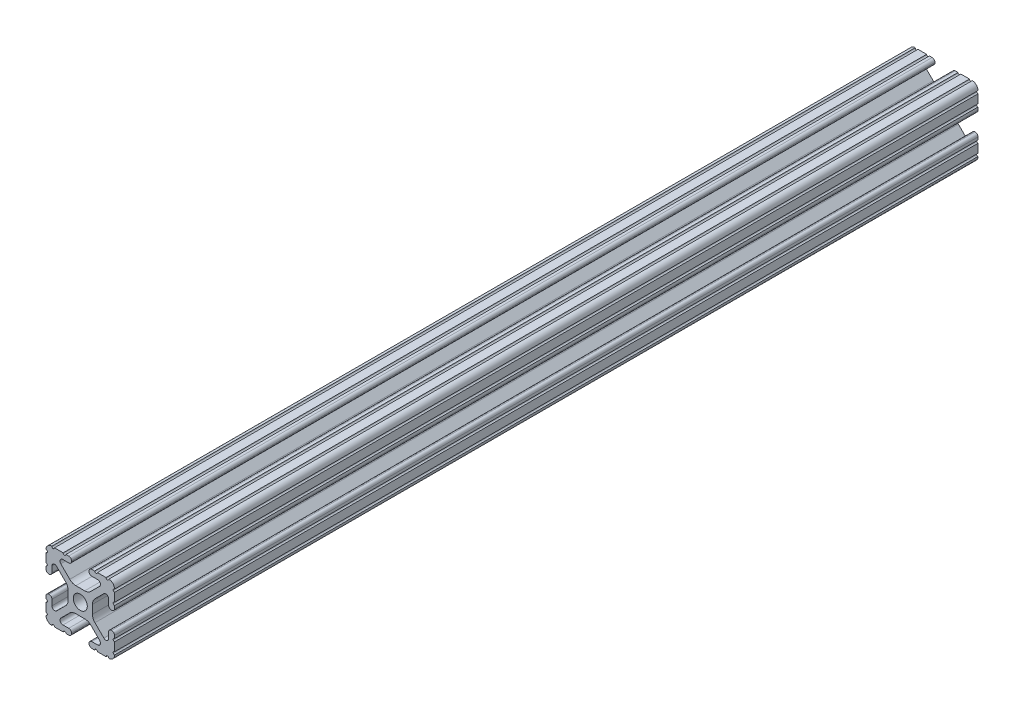
from build123d import *

# Parameters (mm, degrees)
SKETCH1_R      = 2.6035
EXTRUDE1_DEPTH = 320


with BuildPart() as part:
    # Sketch1 → Extrude1 (new body)
    with BuildSketch(Plane.XY):
        with BuildLine():
            Line((-7.207036008, 8.724370562), (-3.898272566, 5.423169045))
            ThreePointArc((-3.898272566, 5.423169045), (-2.869120213, 4.736787962), (-1.655778399, 4.4958))
            Line((-1.655778399, 4.4958), (1.655778399, 4.4958))
            ThreePointArc((1.655778399, 4.4958), (2.869120213, 4.736787962), (3.898272566, 5.423169045))
            Line((3.898272566, 5.423169045), (7.207036008, 8.724370562))
            ThreePointArc((7.207036008, 8.724370562), (7.432222385, 9.85140422), (6.476788598, 10.4902))
            Line((6.476788598, 10.4902), (4.287512407, 10.4902))
            ThreePointArc((4.287512407, 10.4902), (3.54574862, 10.79744862), (3.2385, 11.539212407))
            Line((3.2385, 11.539212407), (3.2385, 11.650987593))
            ThreePointArc((3.2385, 11.650987593), (3.54574862, 12.39275138), (4.287512407, 12.7))
            Line((4.287512407, 12.7), (5.317126718, 12.7))
            ThreePointArc((5.317126718, 12.7), (5.825126718, 12.192), (6.333126718, 12.7))
            Line((6.333126718, 12.7), (9.550443118, 12.7))
            ThreePointArc((9.550443118, 12.7), (10.058366869, 12.192000006), (10.566443095, 12.699847501))
            ThreePointArc((10.566443095, 12.699847501), (12.082537762, 12.08250727), (12.699846982, 10.566399977))
            ThreePointArc((12.699846982, 10.566399977), (12.192000006, 10.058323491), (12.7, 9.5504))
            Line((12.7, 9.5504), (12.7, 6.3330836))
            ThreePointArc((12.7, 6.3330836), (12.192, 5.8250836), (12.7, 5.3170836))
            Line((12.7, 5.3170836), (12.7, 4.287469289))
            ThreePointArc((12.7, 4.287469289), (12.39275138, 3.545705502), (11.650987593, 3.238456882))
            Line((11.650987593, 3.238456882), (11.539212407, 3.238456882))
            ThreePointArc((11.539212407, 3.238456882), (10.79744862, 3.545705502), (10.4902, 4.287469289))
            Line((10.4902, 4.287469289), (10.4902, 6.402089023))
            ThreePointArc((10.4902, 6.402089023), (9.856505071, 7.351067942), (8.737131347, 7.129408934))
            Line((8.737131347, 7.129408934), (5.441005833, 3.840816462))
            ThreePointArc((5.441005833, 3.840816462), (4.750877967, 2.809883091), (4.5085, 1.593185507))
            Line((4.5085, 1.593185507), (4.5085, -1.593185507))
            ThreePointArc((4.5085, -1.593185507), (4.750877967, -2.809883091), (5.441005833, -3.840816462))
            Line((5.441005833, -3.840816462), (8.737131347, -7.129408934))
            ThreePointArc((8.737131347, -7.129408934), (9.856505071, -7.351067942), (10.4902, -6.402089023))
            Line((10.4902, -6.402089023), (10.4902, -4.287469289))
            ThreePointArc((10.4902, -4.287469289), (10.79744862, -3.545705502), (11.539212407, -3.238456882))
            Line((11.539212407, -3.238456882), (11.650987593, -3.238456882))
            ThreePointArc((11.650987593, -3.238456882), (12.39275138, -3.545705502), (12.7, -4.287469289))
            Line((12.7, -4.287469289), (12.7, -5.3170836))
            ThreePointArc((12.7, -5.3170836), (12.192, -5.8250836), (12.7, -6.3330836))
            Line((12.7, -6.3330836), (12.7, -9.5504))
            ThreePointArc((12.7, -9.5504), (12.192000006, -10.058323491), (12.699846982, -10.566399977))
            ThreePointArc((12.699846982, -10.566399977), (12.082537762, -12.08250727), (10.566443095, -12.699847501))
            ThreePointArc((10.566443095, -12.699847501), (10.058366869, -12.192000006), (9.550443118, -12.7))
            Line((9.550443118, -12.7), (6.333126718, -12.7))
            ThreePointArc((6.333126718, -12.7), (5.825126718, -12.192), (5.317126718, -12.7))
            Line((5.317126718, -12.7), (4.287512407, -12.7))
            ThreePointArc((4.287512407, -12.7), (3.54574862, -12.39275138), (3.2385, -11.650987593))
            Line((3.2385, -11.650987593), (3.2385, -11.539212407))
            ThreePointArc((3.2385, -11.539212407), (3.54574862, -10.79744862), (4.287512407, -10.4902))
            Line((4.287512407, -10.4902), (6.416408329, -10.4902))
            ThreePointArc((6.416408329, -10.4902), (7.41473083, -9.822813117), (7.179650497, -8.645192506))
            Line((7.179650497, -8.645192506), (3.952270251, -5.423690499))
            ThreePointArc((3.952270251, -5.423690499), (2.922936451, -4.736929036), (1.709253557, -4.4958))
            Line((1.709253557, -4.4958), (-1.709253557, -4.4958))
            ThreePointArc((-1.709253557, -4.4958), (-2.922936451, -4.736929036), (-3.952270251, -5.423690499))
            Line((-3.952270251, -5.423690499), (-7.179650497, -8.645192506))
            ThreePointArc((-7.179650497, -8.645192506), (-7.41473083, -9.822813117), (-6.416408329, -10.4902))
            Line((-6.416408329, -10.4902), (-4.287512407, -10.4902))
            ThreePointArc((-4.287512407, -10.4902), (-3.54574862, -10.79744862), (-3.2385, -11.539212407))
            Line((-3.2385, -11.539212407), (-3.2385, -11.650987593))
            ThreePointArc((-3.2385, -11.650987593), (-3.54574862, -12.39275138), (-4.287512407, -12.7))
            Line((-4.287512407, -12.7), (-5.317126718, -12.7))
            ThreePointArc((-5.317126718, -12.7), (-5.825126718, -12.192), (-6.333126718, -12.7))
            Line((-6.333126718, -12.7), (-9.550443118, -12.7))
            ThreePointArc((-9.550443118, -12.7), (-10.058366869, -12.192000006), (-10.566443095, -12.699847501))
            ThreePointArc((-10.566443095, -12.699847501), (-12.082537762, -12.08250727), (-12.699846982, -10.566399977))
            ThreePointArc((-12.699846982, -10.566399977), (-12.192000006, -10.058323491), (-12.7, -9.5504))
            Line((-12.7, -9.5504), (-12.7, -6.3330836))
            ThreePointArc((-12.7, -6.3330836), (-12.192, -5.8250836), (-12.7, -5.3170836))
            Line((-12.7, -5.3170836), (-12.7, -4.287469289))
            ThreePointArc((-12.7, -4.287469289), (-12.39275138, -3.545705502), (-11.650987593, -3.238456882))
            Line((-11.650987593, -3.238456882), (-11.539212407, -3.238456882))
            ThreePointArc((-11.539212407, -3.238456882), (-10.79744862, -3.545705502), (-10.4902, -4.287469289))
            Line((-10.4902, -4.287469289), (-10.4902, -6.402089023))
            ThreePointArc((-10.4902, -6.402089023), (-9.856505071, -7.351067942), (-8.737131347, -7.129408934))
            Line((-8.737131347, -7.129408934), (-5.441005833, -3.840816462))
            ThreePointArc((-5.441005833, -3.840816462), (-4.750877967, -2.809883091), (-4.5085, -1.593185507))
            Line((-4.5085, -1.593185507), (-4.5085, 1.593185507))
            ThreePointArc((-4.5085, 1.593185507), (-4.750877967, 2.809883091), (-5.441005833, 3.840816462))
            Line((-5.441005833, 3.840816462), (-8.737131347, 7.129408934))
            ThreePointArc((-8.737131347, 7.129408934), (-9.856505071, 7.351067942), (-10.4902, 6.402089023))
            Line((-10.4902, 6.402089023), (-10.4902, 4.287469289))
            ThreePointArc((-10.4902, 4.287469289), (-10.79744862, 3.545705502), (-11.539212407, 3.238456882))
            Line((-11.539212407, 3.238456882), (-11.650987593, 3.238456882))
            ThreePointArc((-11.650987593, 3.238456882), (-12.39275138, 3.545705502), (-12.7, 4.287469289))
            Line((-12.7, 4.287469289), (-12.7, 5.3170836))
            ThreePointArc((-12.7, 5.3170836), (-12.192, 5.8250836), (-12.7, 6.3330836))
            Line((-12.7, 6.3330836), (-12.7, 9.5504))
            ThreePointArc((-12.7, 9.5504), (-12.192000006, 10.058323491), (-12.699846982, 10.566399977))
            ThreePointArc((-12.699846982, 10.566399977), (-12.082537762, 12.08250727), (-10.566443095, 12.699847501))
            ThreePointArc((-10.566443095, 12.699847501), (-10.058366869, 12.192000006), (-9.550443118, 12.7))
            Line((-9.550443118, 12.7), (-6.333126718, 12.7))
            ThreePointArc((-6.333126718, 12.7), (-5.825126718, 12.192), (-5.317126718, 12.7))
            Line((-5.317126718, 12.7), (-4.287512407, 12.7))
            ThreePointArc((-4.287512407, 12.7), (-3.54574862, 12.39275138), (-3.2385, 11.650987593))
            Line((-3.2385, 11.650987593), (-3.2385, 11.539212407))
            ThreePointArc((-3.2385, 11.539212407), (-3.54574862, 10.79744862), (-4.287512407, 10.4902))
            Line((-4.287512407, 10.4902), (-6.476788598, 10.4902))
            ThreePointArc((-6.476788598, 10.4902), (-7.432222385, 9.85140422), (-7.207036008, 8.724370562))
        make_face()
        Circle(SKETCH1_R, mode=Mode.SUBTRACT)
    extrude(amount=-EXTRUDE1_DEPTH)


solid = part.part
